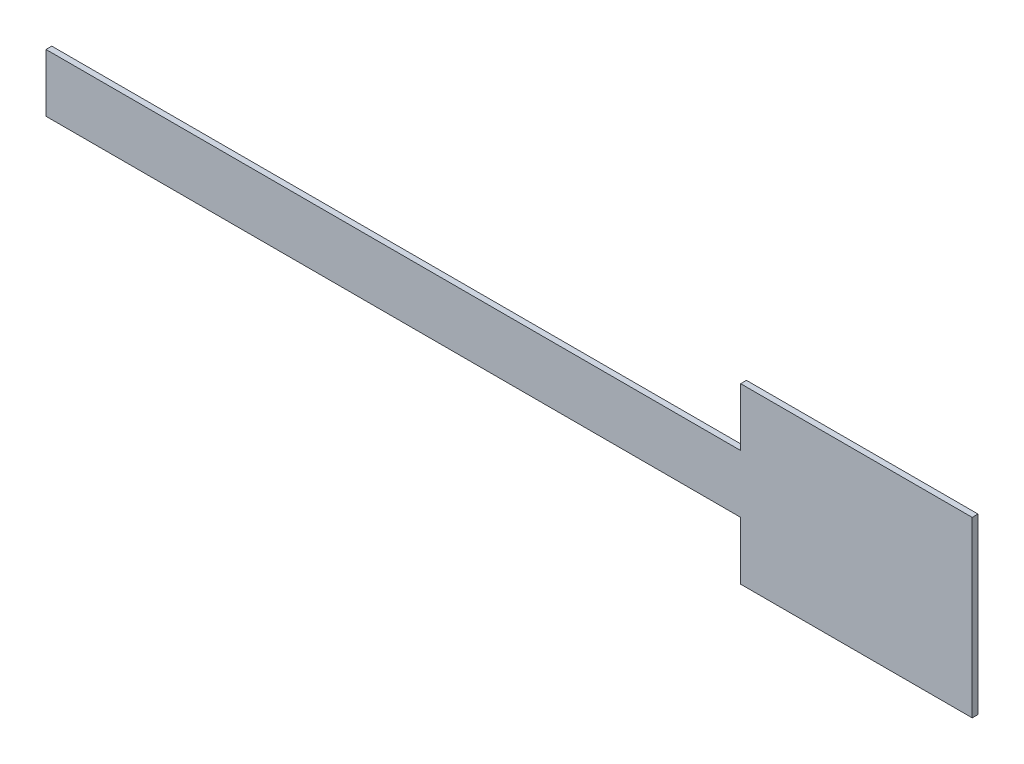
from build123d import *

# Parameters (mm, degrees)
BOSS_EXTRUDE2_DEPTH = 2.54


with BuildPart() as part:
    # Sketch1 → Boss-Extrude2 (new body)
    with BuildSketch(Plane.XY):
        Polygon((66.816138218, 0.686513851), (66.816138218, -24.713486149), (168.416138218, -24.713486149), (168.416138218, 51.486513851), (66.816138218, 51.486513851), (66.816138218, 26.086513851), (-237.983861782, 26.086513851), (-237.983861782, 0.686513851), align=None)
    extrude(amount=BOSS_EXTRUDE2_DEPTH)


solid = part.part
